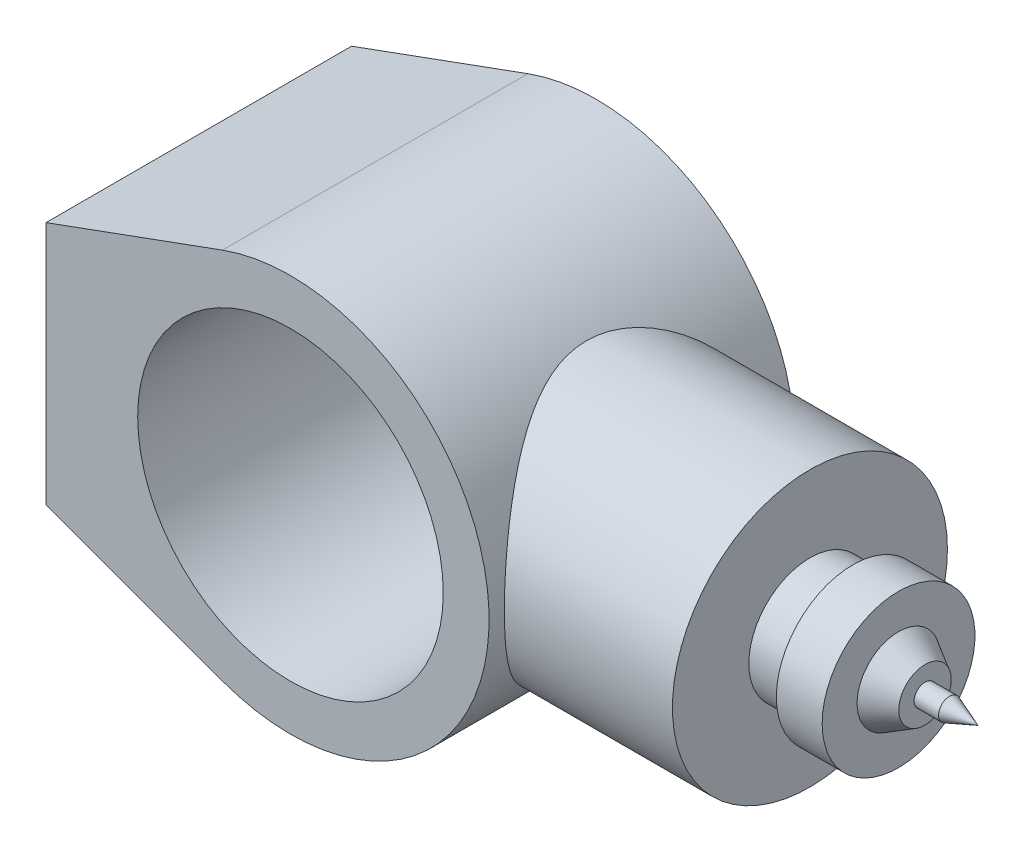
from build123d import *

# Parameters (mm, degrees)
SKETCH1_R           = 50
BOSS_EXTRUDE1_DEPTH = 50
BOSS_EXTRUDE2_REACH = 202
SKETCH2_R           = 45


with BuildPart() as part:
    # Sketch1 → Boss-Extrude1 (new body, symmetric)
    with BuildSketch(Plane.XY):
        with BuildLine():
            Line((-80, -40), (-80, 40))
            Line((-80, 40), (-22.281665693, 61.061668614))
            ThreePointArc((-22.281665693, 61.061668614), (65, 0), (-22.281665693, -61.061668614))
            Line((-22.281665693, -61.061668614), (-80, -40))
        make_face()
        Circle(SKETCH1_R, mode=Mode.SUBTRACT)
    extrude(amount=BOSS_EXTRUDE1_DEPTH, both=True)

    # Sketch2 → Boss-Extrude2 (add, up to next)
    with BuildSketch(Plane(origin=(120, 0, 0), x_dir=(0, 0, -1), z_dir=(1, 0, 0)), mode=Mode.PRIVATE) as boss_extrude2_sk1:
        Circle(SKETCH2_R)
    boss_extrude2_tool1 = extrude(boss_extrude2_sk1.sketch, amount=-BOSS_EXTRUDE2_REACH, mode=Mode.PRIVATE) - part.part
    add(boss_extrude2_tool1.solids().sort_by_distance((120, 0, 0))[0])

    # Sketch5 → Revolve1 (revolve)
    with BuildSketch(Plane.XY):
        Polygon((120, 0), (120, -20), (134, -20), (134, -25), (149, -25), (149, -13.573394096), (157.660254038, -8.573394096), (157.660254038, -3.573394096), (165.660254038, -3.573394096), (175, 0), align=None)
    revolve(axis=Axis((0, 0, 0), (1, 0, 0)))


solid = part.part
